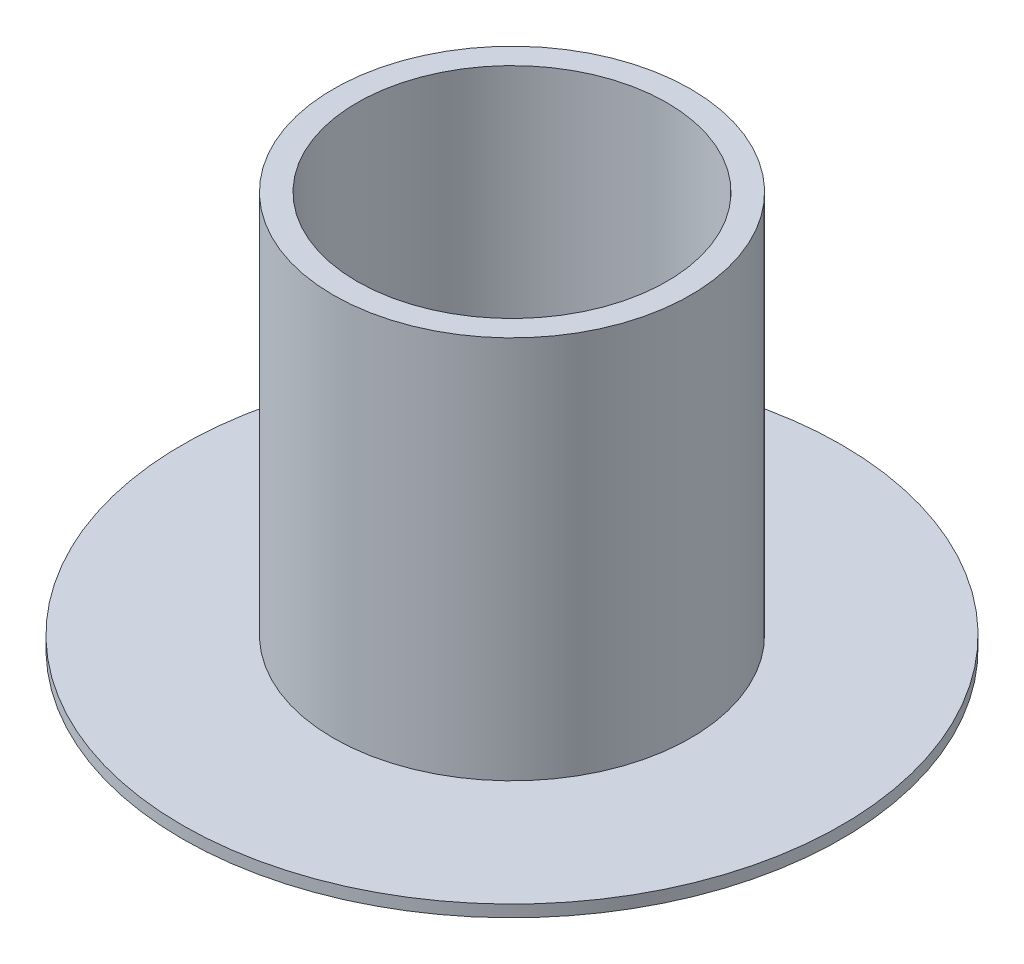
from build123d import *


with BuildPart() as part:
    # Croquis1 → Revolución1 (revolve)
    with BuildSketch(Plane.XY):
        Polygon((-61.52064239, 11.190988836), (-74.77064239, 11.190988836), (-74.77064239, 12.090988836), (-63.32064239, 12.090988836), (-63.32064239, 41.190988836), (-61.52064239, 41.190988836), align=None)
    revolve(axis=Axis((-49.77064239, 52.511562998, 0), (0, -1, 0)))


solid = part.part
